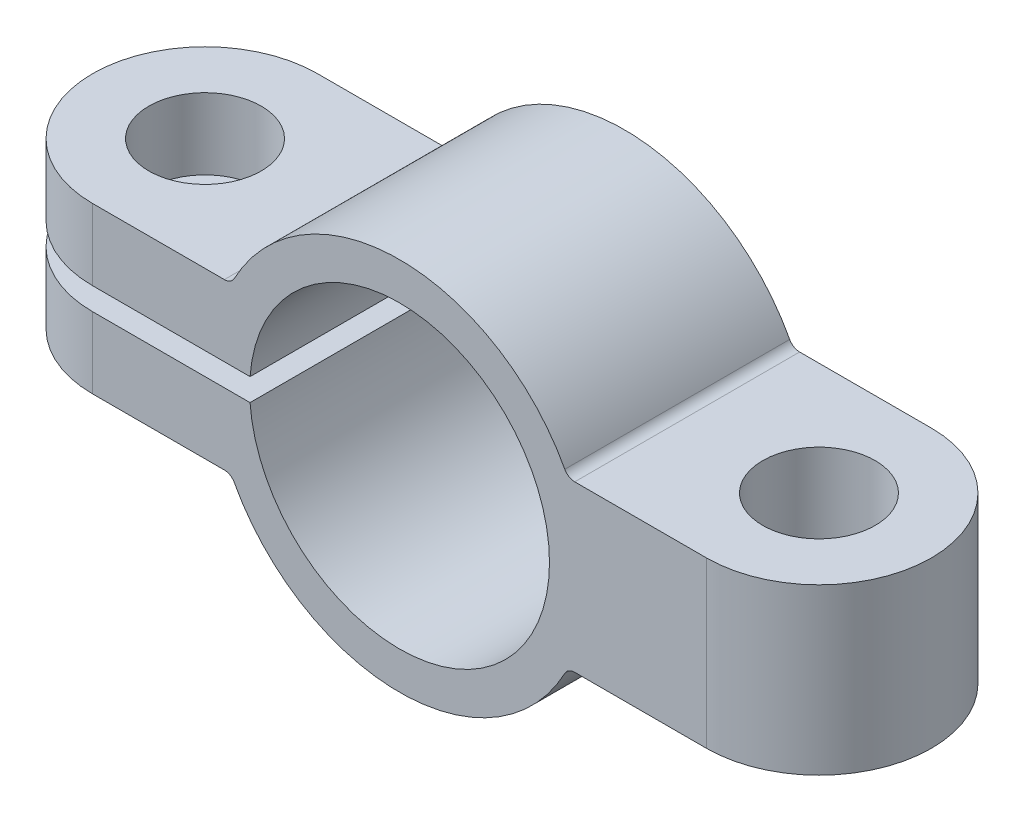
from build123d import *

# Parameters (mm, degrees)
EXTRUDE_1_DEPTH     = 6
CUT_EXTRUDE_1_DEPTH = 8.2
SKETCH_4_R          = 1.5
CUT_EXTRUDE_2_DEPTH = 8.2
FILLET_1_R          = 0.3


with BuildPart() as part:
    # 草图2 → 凸台-拉伸1 (new body)
    with BuildSketch(Plane.XY):
        with BuildLine():
            Line((-11.189988864, 0.3), (-11.189988864, 2.2))
            Line((-11.189988864, 2.2), (-4.489988864, 2.2))
            ThreePointArc((-4.489988864, 2.2), (0, 5), (4.489988864, 2.2))
            Line((4.489988864, 2.2), (11.189988864, 2.2))
            Line((11.189988864, 2.2), (11.189988864, 0))
            Line((11.189988864, 0), (4, 0))
            ThreePointArc((4, 0), (0.150105729, 3.997182541), (-3.988734135, 0.3))
            Line((-3.988734135, 0.3), (-11.189988864, 0.3))
        make_face()
    extrude_1 = extrude(amount=EXTRUDE_1_DEPTH)

    # 镜向2: 凸台-拉伸1 across plane
    add(extrude_1.mirror(Plane.ZX))

    # 草图3 → 切除-拉伸1 (cut, through all)
    with BuildSketch(Plane(origin=(0, 2.2, 0), x_dir=(1, 0, 0), z_dir=(0, 1, 0))):
        with BuildLine():
            ThreePointArc((-11.189988864, -3), (-10.311309208, -0.878679656), (-8.189988864, 0))
            Line((-8.189988864, 0), (-11.189988864, 0))
            Line((-11.189988864, 0), (-11.189988864, -3))
        make_face()
        with BuildLine():
            ThreePointArc((-8.189988864, -6), (-10.311309208, -5.121320344), (-11.189988864, -3))
            Line((-11.189988864, -3), (-11.189988864, -6))
            Line((-11.189988864, -6), (-8.189988864, -6))
        make_face()
    cut_extrude_1 = extrude(amount=-CUT_EXTRUDE_1_DEPTH, mode=Mode.SUBTRACT)

    # 镜向1: 切除-拉伸1 across plane
    add(cut_extrude_1.mirror(Plane(origin=(0, 0, 0), x_dir=(0, 0, 1), z_dir=(1, 0, 0))), mode=Mode.SUBTRACT)

    # 草图4 → 切除-拉伸2 (cut, through all)
    with BuildSketch(Plane(origin=(0, 2.2, 0), x_dir=(1, 0, 0), z_dir=(0, 1, 0))):
        with Locations((-8.189988864, -3)):
            Circle(SKETCH_4_R)
        with Locations((8.189988864, -3)):
            Circle(SKETCH_4_R)
    extrude(amount=-CUT_EXTRUDE_2_DEPTH, mode=Mode.SUBTRACT)

    # 圆角1
    fillet_1_edges = [part.edges().sort_by_distance(p)[0] for p in [
        (-4.489988864, 2.2, 3),
        (4.489988864, 2.2, 3),
        (-4.489988864, -2.2, 3),
        (4.489988864, -2.2, 3),
    ]]
    fillet(fillet_1_edges, radius=FILLET_1_R)


solid = part.part
